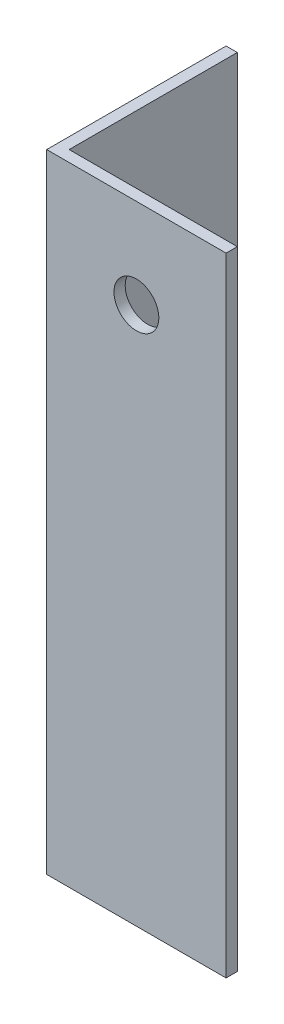
from build123d import *

# Parameters (mm, degrees)
BOSS_EXTRUDE1_DEPTH = 88.9
SKETCH2_R           = 2.54
CUT_EXTRUDE1_DEPTH  = 88.9
SKETCH3_R           = 3.175
CUT_EXTRUDE2_DEPTH  = 88.9


with BuildPart() as part:
    # Sketch1 → Boss-Extrude1 (new body)
    with BuildSketch(Plane(origin=(0, 0, 0), x_dir=(1, 0, 0), z_dir=(0, 1, 0))):
        Polygon((0, 0), (0, 25.4), (1.5875, 25.4), (1.5875, 1.5875), (25.4, 1.5875), (25.4, 0), align=None)
    extrude(amount=BOSS_EXTRUDE1_DEPTH)

    # Sketch2 → Cut-Extrude1 (cut)
    with BuildSketch(Plane.ZY):
        with Locations((-12.7, 38.1)):
            Circle(SKETCH2_R)
        with Locations((-12.7, 12.7)):
            Circle(SKETCH2_R)
    extrude(amount=-CUT_EXTRUDE1_DEPTH, mode=Mode.SUBTRACT)

    # Sketch3 → Cut-Extrude2 (cut)
    with BuildSketch(Plane(origin=(0, 0, -1.5875), x_dir=(-1, 0, 0), z_dir=(0, 0, -1))):
        with Locations((-12.7, 76.2)):
            Circle(SKETCH3_R)
    extrude(amount=-CUT_EXTRUDE2_DEPTH, mode=Mode.SUBTRACT)


solid = part.part
